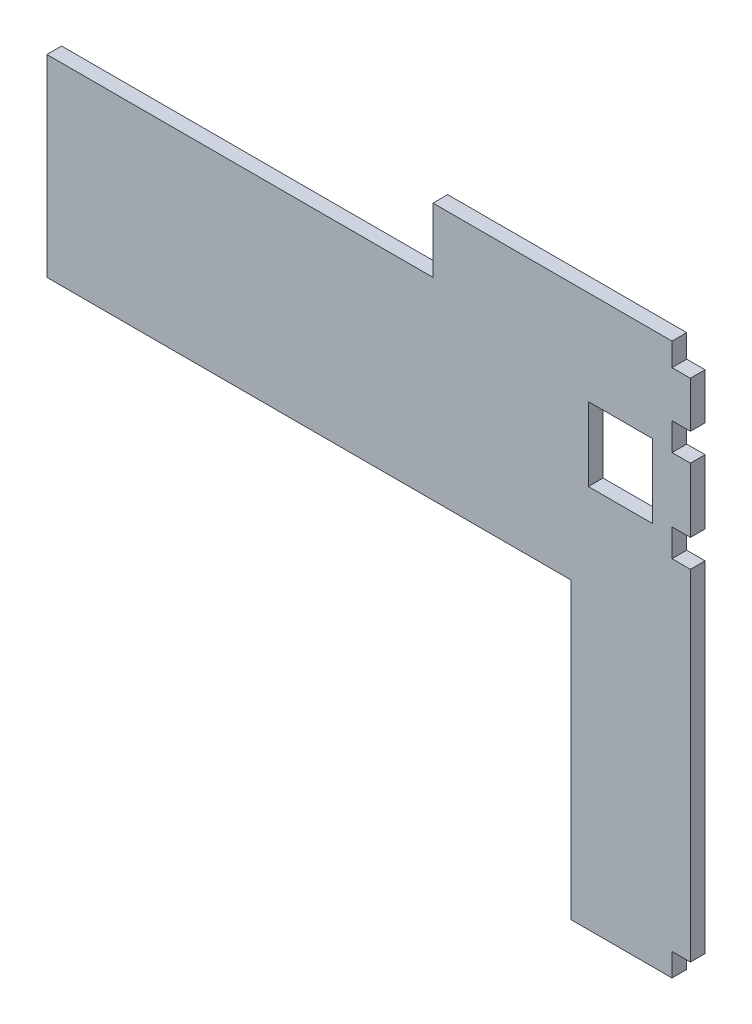
from build123d import *

# Parameters (mm, degrees)
SKETCH1_W           = 680
SKETCH1_H           = 560
BOSS_EXTRUDE1_DEPTH = 16
SKETCH2_W           = 550
SKETCH2_H           = 20
BOSS_EXTRUDE2_DEPTH = 16
SKETCH3_W           = 70
SKETCH3_H           = 80
CUT_EXTRUDE1_DEPTH  = 17
CUT_EXTRUDE2_REACH  = 18
SKETCH4_W           = 570
SKETCH4_H           = 320
SKETCH4_H_2         = 70
SKETCH5_W           = 20
SKETCH5_H           = 50
SKETCH5_H_2         = 70
SKETCH5_H_3         = 370
BOSS_EXTRUDE3_DEPTH = 16
SKETCH6_W           = 150
SKETCH6_H           = 70
BOSS_EXTRUDE4_DEPTH = 16


with BuildPart() as part:
    # Sketch1 → Boss-Extrude1 (new body)
    with BuildSketch(Plane.XY):
        with Locations((340, 280)):
            Rectangle(SKETCH1_W, SKETCH1_H)
    extrude(amount=BOSS_EXTRUDE1_DEPTH)

    # Sketch2 → Boss-Extrude2 (add)
    with BuildSketch(Plane.XY.offset(16)):
        with Locations((405, -10)):
            Rectangle(SKETCH2_W, SKETCH2_H)
        with Locations((405, 570)):
            Rectangle(SKETCH2_W, SKETCH2_H)
    extrude(amount=-BOSS_EXTRUDE2_DEPTH)

    # Sketch3 → Cut-Extrude1 (cut, through all)
    with BuildSketch(Plane.XY.offset(16)):
        with Locations((624, 437.5)):
            Rectangle(SKETCH3_W, SKETCH3_H)
    extrude(amount=-CUT_EXTRUDE1_DEPTH, mode=Mode.SUBTRACT)

    # Sketch4 → Cut-Extrude2 (cut, up to next)
    with BuildSketch(Plane.XY.offset(16), mode=Mode.PRIVATE) as cut_extrude2_sk1:
        with Locations((285, 140)):
            Rectangle(SKETCH4_W, SKETCH4_H)
    cut_extrude2_tool1 = extrude(cut_extrude2_sk1.sketch, amount=-CUT_EXTRUDE2_REACH, mode=Mode.PRIVATE) & part.part
    add(cut_extrude2_tool1.solids().sort_by_distance((285, 140, 16))[0], mode=Mode.SUBTRACT)
    # Sketch4 → Cut-Extrude2 (cut, up to next)
    with BuildSketch(Plane.XY.offset(16), mode=Mode.PRIVATE) as cut_extrude2_sk2:
        with Locations((285, 545)):
            Rectangle(SKETCH4_W, SKETCH4_H_2)
    cut_extrude2_tool2 = extrude(cut_extrude2_sk2.sketch, amount=-CUT_EXTRUDE2_REACH, mode=Mode.PRIVATE) & part.part
    add(cut_extrude2_tool2.solids().sort_by_distance((285, 545, 16))[0], mode=Mode.SUBTRACT)

    # Sketch5 → Boss-Extrude3 (add)
    with BuildSketch(Plane.XY.offset(16)):
        with Locations((690, 530)):
            Rectangle(SKETCH5_W, SKETCH5_H)
        with Locations((690, 440)):
            Rectangle(SKETCH5_W, SKETCH5_H_2)
        with Locations((690, 190)):
            Rectangle(SKETCH5_W, SKETCH5_H_3)
    extrude(amount=-BOSS_EXTRUDE3_DEPTH)

    # Sketch6 → Boss-Extrude4 (add)
    with BuildSketch(Plane.XY.offset(16)):
        with Locations((495, 545)):
            Rectangle(SKETCH6_W, SKETCH6_H)
    extrude(amount=-BOSS_EXTRUDE4_DEPTH)


solid = part.part
